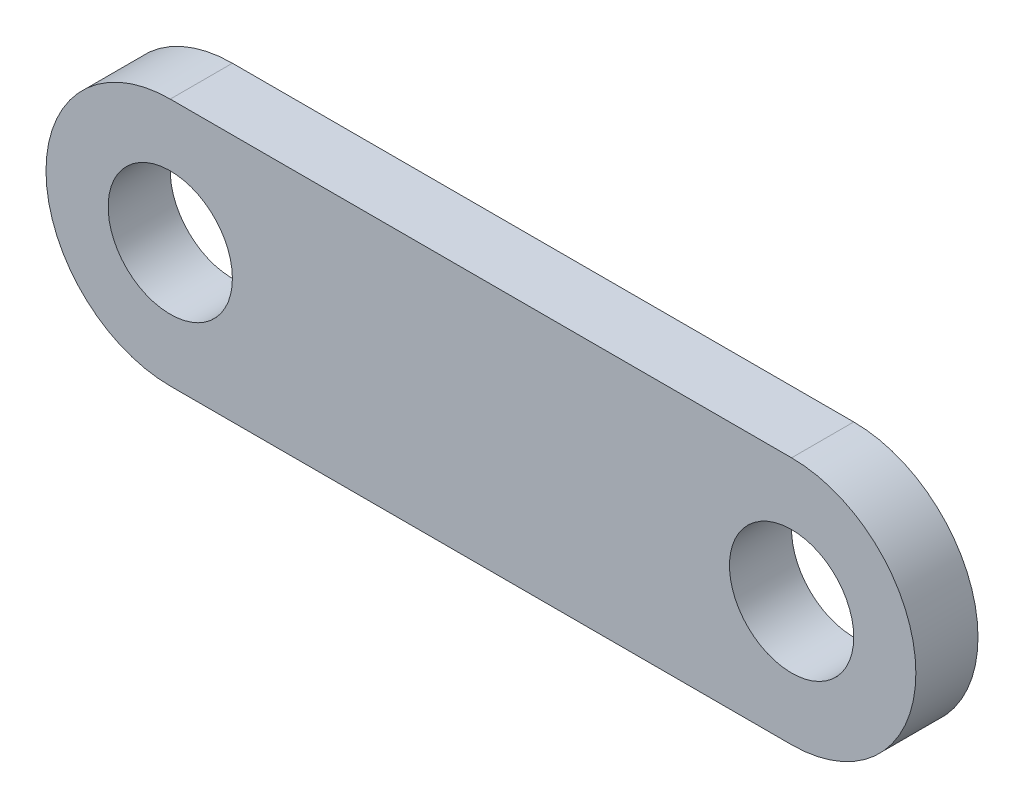
from build123d import *

# Parameters (mm, degrees)
SKETCH1_R           = 2.54
BOSS_EXTRUDE1_DEPTH = 2.54


with BuildPart() as part:
    # Sketch1 → Boss-Extrude1 (new body)
    with BuildSketch(Plane.XY):
        with BuildLine():
            Line((0, -5.08), (-25.4, -5.08))
            ThreePointArc((-25.4, -5.08), (-30.48, 0), (-25.4, 5.08))
            Line((-25.4, 5.08), (0, 5.08))
            ThreePointArc((0, 5.08), (5.08, 0), (0, -5.08))
        make_face()
        with Locations((-25.4, 0)):
            Circle(SKETCH1_R, mode=Mode.SUBTRACT)
        Circle(SKETCH1_R, mode=Mode.SUBTRACT)
    extrude(amount=BOSS_EXTRUDE1_DEPTH)


solid = part.part
